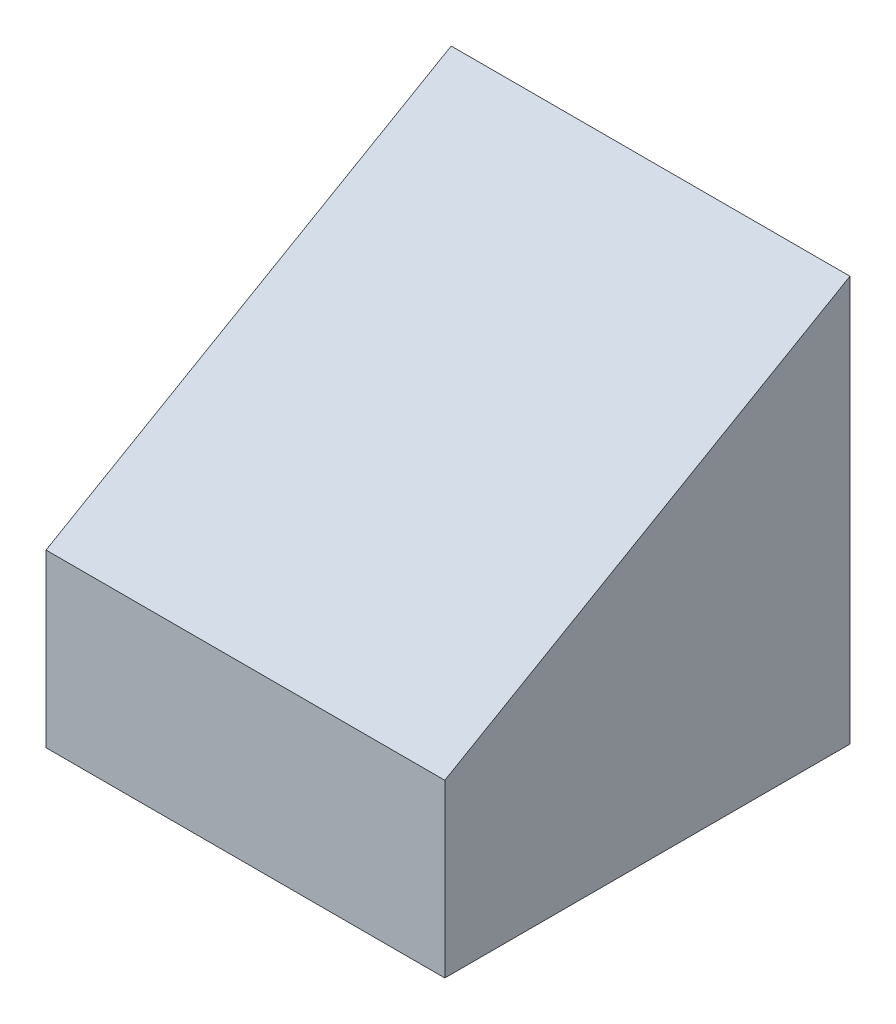
from build123d import *

# Parameters (mm, degrees)
BOSS_EXTRUDE1_DEPTH        = 12.5
F_10_24_TAPPED_HOLE2_D     = 3.7973
F_10_24_TAPPED_HOLE2_DEPTH = 12.83
F_10_24_TAPPED_HOLE2_TIP   = 1.140824014


with BuildPart() as part:
    # Sketch1 → Boss-Extrude1 (new body, symmetric)
    with BuildSketch(Plane(origin=(0, 0, 0), x_dir=(0, 0, -1), z_dir=(1, 0, 0))):
        Polygon((0, 0), (0, 25.4), (-25.4, 10.735303163), (-25.4, 0), align=None)
    extrude(amount=BOSS_EXTRUDE1_DEPTH, both=True)

    # #10-24 Tapped Hole2
    with Locations(Plane(origin=(0, 0, 0), x_dir=(-1, 0, 0), z_dir=(0, -1, 0))):
        with Locations((105.780967711, 37.577069838), (0, -12.7)):
            Hole(F_10_24_TAPPED_HOLE2_D / 2, depth=F_10_24_TAPPED_HOLE2_DEPTH)
            with Locations((0, 0, -(F_10_24_TAPPED_HOLE2_DEPTH + F_10_24_TAPPED_HOLE2_TIP / 2))):  # 118° drill point
                Cone(0, F_10_24_TAPPED_HOLE2_D / 2, F_10_24_TAPPED_HOLE2_TIP, mode=Mode.SUBTRACT)


solid = part.part
